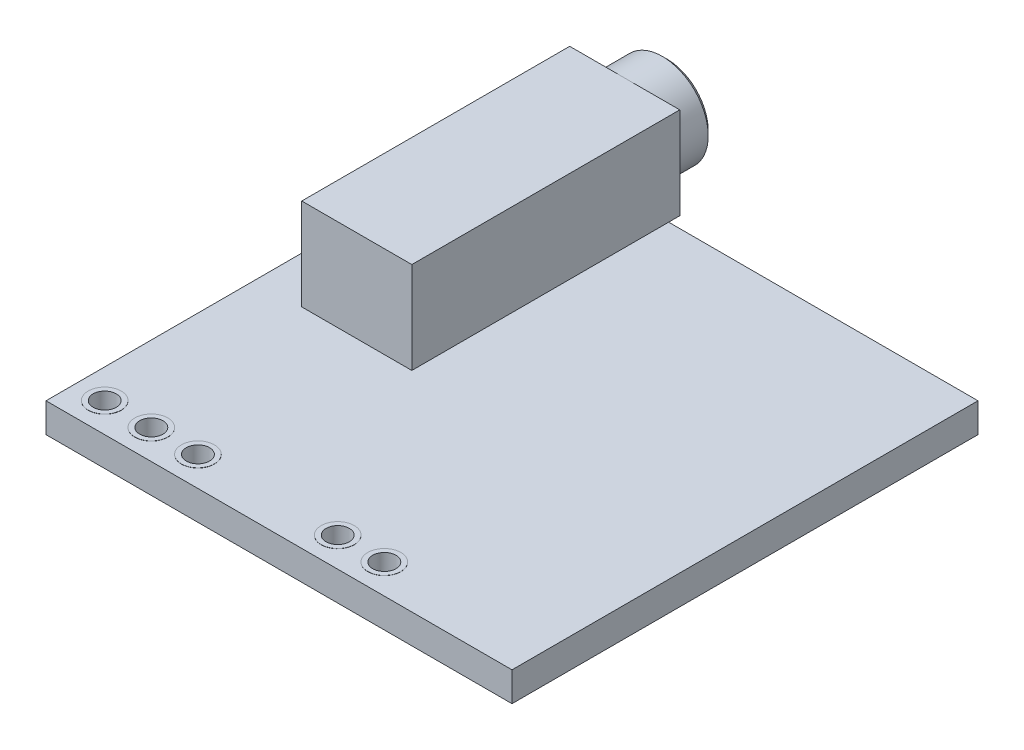
from build123d import *

# Parameters (mm, degrees)
SKETCH1_W           = 25.4
SKETCH1_H           = 25.4
BOSS_EXTRUDE1_DEPTH = 0.8001
SKETCH2_R           = 0.635
CUT_EXTRUDE1_DEPTH  = 1.6002
SKETCH3_W           = 6
SKETCH3_H           = 14.605
BOSS_EXTRUDE2_DEPTH = 5
SKETCH4_R           = 2.5
BOSS_EXTRUDE3_DEPTH = 2.3
SKETCH5_R           = 1.75
CUT_EXTRUDE4_DEPTH  = 15.905
CHAMFER1_SIZE       = 0.25
SKETCH6_R           = 0.9
SKETCH6_R_2         = 0.635
BOSS_EXTRUDE4_DEPTH = 0.01


with BuildPart() as part:
    # Sketch1 → Boss-Extrude1 (new body, symmetric)
    with BuildSketch(Plane(origin=(0, 0, 0), x_dir=(1, 0, 0), z_dir=(0, 1, 0))):
        Rectangle(SKETCH1_W, SKETCH1_H)
    extrude(amount=BOSS_EXTRUDE1_DEPTH, both=True)

    # Sketch2 → Cut-Extrude1 (cut)
    with BuildSketch(Plane(origin=(0, 0.8001, 0), x_dir=(1, 0, 0), z_dir=(0, 1, 0))):
        with Locations((-11.0998, -11.0998)):
            Circle(SKETCH2_R)
        with Locations((-8.5598, -11.0998)):
            Circle(SKETCH2_R)
        with Locations((-6.0198, -11.0998)):
            Circle(SKETCH2_R)
        with Locations((1.6002, -11.0998)):
            Circle(SKETCH2_R)
        with Locations((4.1402, -11.0998)):
            Circle(SKETCH2_R)
    extrude(amount=-CUT_EXTRUDE1_DEPTH, mode=Mode.SUBTRACT)

    # Sketch3 → Boss-Extrude2 (add)
    with BuildSketch(Plane(origin=(0, 0.8001, 0), x_dir=(1, 0, 0), z_dir=(0, 1, 0))):
        with Locations((-7.16, 6.0025)):
            Rectangle(SKETCH3_W, SKETCH3_H)
    extrude(amount=BOSS_EXTRUDE2_DEPTH)

    # Sketch4 → Boss-Extrude3 (add)
    with BuildSketch(Plane(origin=(0, 0, -13.305), x_dir=(-1, 0, 0), z_dir=(0, 0, -1))):
        with Locations((7.16, 3.3001)):
            Circle(SKETCH4_R)
    extrude(amount=BOSS_EXTRUDE3_DEPTH)

    # Sketch5 → Cut-Extrude4 (cut)
    with BuildSketch(Plane(origin=(0, 0, -15.605), x_dir=(-1, 0, 0), z_dir=(0, 0, -1))):
        with Locations((7.16, 3.3001)):
            Circle(SKETCH5_R)
    extrude(amount=-CUT_EXTRUDE4_DEPTH, mode=Mode.SUBTRACT)

    # Chamfer1
    chamfer1_edges = [part.edges().sort_by_distance(p)[0] for p in [
        (-4.66, 3.3001, -15.605),
    ]]
    chamfer(chamfer1_edges, length=CHAMFER1_SIZE)

    # Sketch6 → Boss-Extrude4 (add)
    with BuildSketch(Plane(origin=(0, 0.8001, 0), x_dir=(1, 0, 0), z_dir=(0, 1, 0))):
        with Locations((-11.0998, -11.0998)):
            Circle(SKETCH6_R)
        with Locations((-11.0998, -11.0998)):
            Circle(SKETCH6_R_2, mode=Mode.SUBTRACT)
        with Locations((-8.5598, -11.0998)):
            Circle(SKETCH6_R)
        with Locations((-8.5598, -11.0998)):
            Circle(SKETCH6_R_2, mode=Mode.SUBTRACT)
        with Locations((-6.0198, -11.0998)):
            Circle(SKETCH6_R)
        with Locations((-6.0198, -11.0998)):
            Circle(SKETCH6_R_2, mode=Mode.SUBTRACT)
        with Locations((1.6002, -11.0998)):
            Circle(SKETCH6_R)
        with Locations((1.6002, -11.0998)):
            Circle(SKETCH6_R_2, mode=Mode.SUBTRACT)
        with Locations((4.1402, -11.0998)):
            Circle(SKETCH6_R)
        with Locations((4.1402, -11.0998)):
            Circle(SKETCH6_R_2, mode=Mode.SUBTRACT)
    boss_extrude4 = extrude(amount=BOSS_EXTRUDE4_DEPTH)

    # Mirror1: Boss-Extrude4 across plane
    add(boss_extrude4.mirror(Plane.ZX))


solid = part.part
